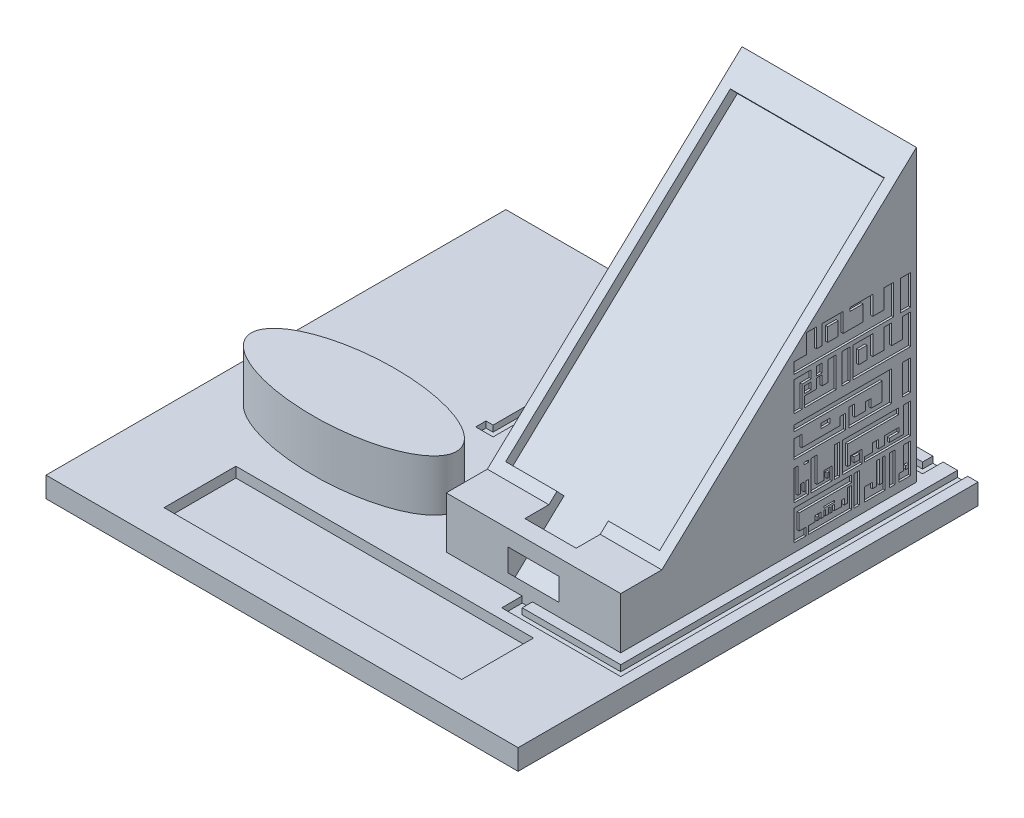
from build123d import *

# Parameters (mm, degrees)
SKETCH1_W           = 230
SKETCH1_H           = 224.05
BOSS_EXTRUDE1_DEPTH = 10
SKETCH1_5_RX        = 50
SKETCH1_5_RY        = 20
BOSS_EXTRUDE2_DEPTH = 25
SKETCH1_6_W         = 85
SKETCH1_6_H         = 144.05
BOSS_EXTRUDE3_DEPTH = 25
SKETCH1_8_W         = 145
SKETCH1_8_H         = 35
CUT_EXTRUDE1_DEPTH  = 5
BOSS_EXTRUDE6_START = -85
BOSS_EXTRUDE6_DEPTH = 85
SKETCH5_W           = 75
SKETCH5_H           = 150
CUT_EXTRUDE2_DEPTH  = 5
SKETCH5_3_W         = 25
SKETCH5_3_H         = 32.573742965
CUT_EXTRUDE3_DEPTH  = 8
SKETCH6_W           = 25
SKETCH6_H           = 32.807391054
CUT_EXTRUDE4_DEPTH  = 5
CUT_EXTRUDE5_DEPTH  = 3
CUT_EXTRUDE6_DEPTH  = 3
SKETCH14_W          = 5.229620034
SKETCH14_H          = 4.516490029
SKETCH14_W_2        = 4.754232759
SKETCH14_H_2        = 13.311760086
SKETCH14_W_3        = 4.754200031
SKETCH14_H_3        = 4.873055031
SKETCH14_W_4        = 55.86185036
SKETCH14_H_4        = 5.229620033
SKETCH14_H_5        = 4.783913781
SKETCH14_H_6        = 4.75420003
SKETCH14_W_5        = 4.991910032
SKETCH14_H_7        = 5.467330035
CUT_EXTRUDE7_DEPTH  = 3
SKETCH17_W          = 4.784873494
SKETCH17_H          = 14.625062341
SKETCH17_W_2        = 5.056431727
SKETCH17_H_2        = 6.616613386
SKETCH17_W_3        = 4.033370346
SKETCH17_H_3        = 6.231694953
SKETCH17_W_4        = 3.850934299
SKETCH17_W_5        = 4.288159487
SKETCH17_H_4        = 2.311035872
SKETCH17_W_6        = 2.611427715
SKETCH17_H_5        = 2.528019296
SKETCH17_W_7        = 1.087445954
SKETCH17_H_6        = 2.328438825
SKETCH17_W_8        = 1.416095815
SKETCH17_H_7        = 1.630432615
SKETCH17_W_9        = 2.674999894
SKETCH17_W_10       = 1.152737166
SKETCH17_W_11       = 2.717633131
SKETCH17_H_8        = 4.191921215
SKETCH17_W_12       = 3.241166829
SKETCH17_H_9        = 3.24997267
SKETCH17_W_13       = 2.608209419
SKETCH17_W_14       = 2.105340551
SKETCH17_H_10       = 1.029150801
SKETCH17_W_15       = 5.118075179
SKETCH17_H_11       = 0.779004841
CUT_EXTRUDE9_DEPTH  = 1
SKETCH18_W          = 210
SKETCH18_H          = 45.56820705
SKETCH18_W_2        = 57.268152104
SKETCH18_H_2        = 92.9135859
CUT_EXTRUDE10_DEPTH = 3


with BuildPart() as part:
    # Sketch1 → Boss-Extrude1 (new body)
    with BuildSketch(Plane(origin=(0, 0, 0), x_dir=(1, 0, 0), z_dir=(0, 1, 0))):
        with Locations((24.512599184, 69.589828777)):
            Rectangle(SKETCH1_W, SKETCH1_H)
    extrude(amount=-BOSS_EXTRUDE1_DEPTH)

    # Sketch1_5 → Boss-Extrude2 (add)
    with BuildSketch(Plane(origin=(0, 0, 0), x_dir=(1, 0, 0), z_dir=(0, 1, 0))):
        with Locations(Location((-25.487400816, 42.564828777), (0, 0, 0))):
            Ellipse(SKETCH1_5_RX, SKETCH1_5_RY)
    extrude(amount=BOSS_EXTRUDE2_DEPTH)

    # Sketch1_6 → Boss-Extrude3 (add)
    with BuildSketch(Plane(origin=(0, 0, 0), x_dir=(1, 0, 0), z_dir=(0, 1, 0))):
        with Locations((82.012599184, 94.589828777)):
            Rectangle(SKETCH1_6_W, SKETCH1_6_H)
    extrude(amount=BOSS_EXTRUDE3_DEPTH)

    # Sketch1_8 → Cut-Extrude1 (cut)
    with BuildSketch(Plane(origin=(0, 0, 0), x_dir=(1, 0, 0), z_dir=(0, 1, 0))):
        with Locations((24.512599184, -9.935171223)):
            Rectangle(SKETCH1_8_W, SKETCH1_8_H)
    extrude(amount=-CUT_EXTRUDE1_DEPTH, mode=Mode.SUBTRACT)

    # Sketch3 → Boss-Extrude6 (add)
    with BuildSketch(Plane.ZY.offset(-39.512599184).offset(BOSS_EXTRUDE6_START)):
        Polygon((-166.618882831, 25), (-166.618882831, 141.235070752), (-42.564828777, 25), align=None)
    extrude(amount=BOSS_EXTRUDE6_DEPTH)

    # Sketch5 → Cut-Extrude2 (cut)
    with BuildSketch(Plane(origin=(0, -7.924755547, -7.425267387), x_dir=(1, 0, 0), z_dir=(0, 0.72972973, 0.68373571))):
        with Locations((82.012599184, 128.554197404)):
            Rectangle(SKETCH5_W, SKETCH5_H)
    extrude(amount=-CUT_EXTRUDE2_DEPTH, mode=Mode.SUBTRACT)

    # Sketch5_3 → Cut-Extrude3 (cut)
    with BuildSketch(Plane(origin=(0, -7.924755547, -7.425267387), x_dir=(1, 0, 0), z_dir=(0, 0.72972973, 0.68373571))):
        with Locations((82.012599184, 31.867342275)):
            Rectangle(SKETCH5_3_W, SKETCH5_3_H)
    extrude(amount=CUT_EXTRUDE3_DEPTH, mode=Mode.SUBTRACT)

    # Sketch6 → Cut-Extrude4 (cut)
    with BuildSketch(Plane(origin=(0, -7.924755547, -7.425267387), x_dir=(1, 0, 0), z_dir=(0, 0.72972973, 0.68373571))):
        with Locations((82.012599184, 37.150501877)):
            Rectangle(SKETCH6_W, SKETCH6_H)
    extrude(amount=-CUT_EXTRUDE4_DEPTH, mode=Mode.SUBTRACT)

    # Sketch7 → Cut-Extrude5 (cut)
    with BuildSketch(Plane(origin=(0, 0, 0), x_dir=(1, 0, 0), z_dir=(0, 1, 0))):
        Polygon((81.512599184, 22.564828777), (76.512599184, 22.564828777), (76.512599184, 12.564828777), (134.512599184, 12.564828777), (134.512599184, 181.614828777), (129.512599184, 181.614828777), (129.512599184, 17.564828777), (81.512599184, 17.564828777), align=None)
    extrude(amount=-CUT_EXTRUDE5_DEPTH, mode=Mode.SUBTRACT)

    # Sketch7_3 → Cut-Extrude6 (cut)
    with BuildSketch(Plane(origin=(0, 0, 0), x_dir=(1, 0, 0), z_dir=(0, 1, 0))):
        Polygon((122.512599184, 181.614828777), (122.512599184, 171.614828777), (2.319740426, 171.614828777), (2.319740426, 82.564828777), (-6.151618198, 82.564828777), (-6.151618198, 87.564828777), (-2.680259574, 87.564828777), (-2.680259574, 176.614828777), (117.512599184, 176.614828777), (117.512599184, 181.614828777), align=None)
    extrude(amount=-CUT_EXTRUDE6_DEPTH, mode=Mode.SUBTRACT)

    # Sketch14 → Cut-Extrude7 (cut)
    with BuildSketch(Plane(origin=(0, 0, -166.618882831), x_dir=(-1, 0, 0), z_dir=(0, 0, -1))):
        Polygon((-53.021234882, 137.000333612), (-53.021234882, 122.975443522), (-103.415787935, 122.975443522), (-103.415787935, 103.720933398), (-108.88311797, 103.720933398), (-108.88311797, 136.473295075), (-93.43196787, 136.473295075), (-93.43196787, 127.440315017), (-88.67776784, 127.440315017), (-88.67776784, 136.473295075), (-82.972727803, 136.473295075), (-82.972727803, 127.440315017), (-78.218527772, 127.440315017), (-78.218527772, 136.473295075), (-73.22661774, 136.473295075), (-73.22661774, 127.440315017), (-68.234707708, 127.440315017), (-68.234707708, 136.473295075), (-63.005087674, 136.473295075), (-63.005087674, 127.967353554), (-57.775467641, 127.967353554), (-57.775467641, 137.000333612), align=None)
        with Locations((-100.800977918, 130.225598569)):
            Rectangle(SKETCH14_W, SKETCH14_H, mode=Mode.SUBTRACT)
        with Locations((-55.398351262, 110.376813441)):
            Rectangle(SKETCH14_W_2, SKETCH14_H_2)
        Polygon((-63.005087674, 117.032693484), (-63.005087674, 103.720933398), (-98.186167901, 103.720933398), (-98.186167901, 117.032693484), (-82.972727803, 117.032693484), (-82.972727803, 108.475133429), (-78.218527772, 108.475133429), (-78.218527772, 117.032693484), (-73.22661774, 117.032693484), (-73.22661774, 108.475133429), (-68.234707708, 108.475133429), (-68.234707708, 117.032693484), align=None)
        with Locations((-92.017976124, 110.911660944)):
            Rectangle(SKETCH14_W_3, SKETCH14_H_3, mode=Mode.SUBTRACT)
        with Locations((-81.915301059, 95.876503348)):
            Rectangle(SKETCH14_W_4, SKETCH14_H_4)
        Polygon((-53.984375879, 87.505641567), (-58.73857591, 87.505641567), (-58.73857591, 58.793743109), (-63.968195944, 58.793743109), (-63.968195944, 68.539853172), (-69.197815977, 68.539853172), (-69.197815977, 58.793743109), (-89.640876109, 58.793743109), (-89.640876109, 54.27725308), (-53.984375879, 54.27725308), align=None)
        Polygon((-109.846226239, 88.032073297), (-109.846226239, 84.228713273), (-69.197815977, 84.228713273), (-69.197815977, 78.523673236), (-99.14927617, 78.523673236), (-99.14927617, 58.793743109), (-104.378896204, 58.793743109), (-104.378896204, 78.523673236), (-109.846226239, 78.523673236), (-109.846226239, 54.27725308), (-94.39507614, 54.27725308), (-94.39507614, 73.412908203), (-89.522021108, 73.412908203), (-89.522021108, 63.845080642), (-74.18972601, 63.845080642), (-74.18972601, 73.412908203), (-63.968195944, 73.412908203), (-63.968195944, 88.032073297), align=None)
        with Locations((-81.796446059, 71.020951313)):
            Rectangle(SKETCH14_W_3, SKETCH14_H_5, mode=Mode.SUBTRACT)
        with Locations((-81.915301059, 45.906391299)):
            Rectangle(SKETCH14_W_4, SKETCH14_H_6)
        Polygon((-58.73857591, 38.061961248), (-58.73857591, 9.299051063), (-63.968195944, 9.299051063), (-63.968195944, 19.045161126), (-69.197815977, 19.045161126), (-69.197815977, 9.299051063), (-109.846226239, 9.299051063), (-109.846226239, 4.782561034), (-53.984375879, 4.782561034), (-53.984375879, 38.061961248), align=None)
        Polygon((-79.419346043, 38.061961248), (-63.968195944, 38.061961248), (-63.968195944, 23.680506156), (-89.522021108, 23.680506156), (-89.522021108, 33.307761218), (-94.39507614, 33.307761218), (-94.39507614, 23.680506156), (-104.378896204, 23.680506156), (-104.378896204, 19.045161126), (-76.745108526, 19.045161126), (-76.745108526, 14.172106095), (-109.846226239, 14.172106095), (-109.846226239, 38.061961248), (-84.173546074, 38.061961248), (-84.173546074, 28.494133687), (-69.197815977, 28.494133687), (-69.197815977, 33.278047468), (-79.419346043, 33.278047468), align=None)
        with Locations((-101.882941188, 31.100527931)):
            Rectangle(SKETCH14_W_5, SKETCH14_H_7, mode=Mode.SUBTRACT)
    extrude(amount=-CUT_EXTRUDE7_DEPTH, mode=Mode.SUBTRACT)

    # Sketch17 → Cut-Extrude9 (cut)
    with BuildSketch(Plane(origin=(124.512599184, 0, 0), x_dir=(0, 0, -1), z_dir=(1, 0, 0))):
        with Locations((161.358444461, 82.562943082)):
            Rectangle(SKETCH17_W, SKETCH17_H)
        Polygon((150.701585499, 89.875474252), (155.486458993, 89.875474252), (155.486458993, 75.250411911), (107.031739009, 75.250411911), (107.031739009, 80.566938016), (113.184412967, 80.566938016), (113.184412967, 89.875474252), (117.969286461, 89.875474252), (117.969286461, 80.566938016), (120.731293394, 80.566938016), (120.731293394, 89.875474252), (130.895478905, 89.875474252), (130.895478905, 80.566938016), (140.617743308, 80.566938016), (140.617743308, 88.207938914), (134.314603894, 88.207938914), (134.314603894, 89.875474252), (145.354158386, 89.875474252), (145.354158386, 80.566938016), (150.701585499, 80.566938016), align=None)
        with Locations((125.911035913, 83.875244709)):
            Rectangle(SKETCH17_W_2, SKETCH17_H_2, mode=Mode.SUBTRACT)
        Polygon((159.899946909, 73.250570314), (163.750881208, 73.250570314), (163.750881208, 58.625507973), (159.899946909, 58.625507973), (135.751693469, 58.625507973), (135.751693469, 73.250570314), (145.354158386, 73.250570314), (145.354158386, 63.595554709), (150.701585499, 63.595554709), (150.701585499, 73.250570314), (154.552519797, 73.250570314), (154.552519797, 63.595554709), (159.899946909, 63.595554709), align=None)
        with Locations((140.496529885, 66.711402186)):
            Rectangle(SKETCH17_W_3, SKETCH17_H_3, mode=Mode.SUBTRACT)
        with Locations((132.389136745, 65.938039144)):
            Rectangle(SKETCH17_W_4, SKETCH17_H)
        Polygon((123.580677252, 73.250570314), (123.580677252, 63.595554709), (120.668230643, 63.595554709), (120.668230643, 68.259457278), (117.950597512, 68.259457278), (117.950597512, 63.595554709), (112.089138513, 63.595554709), (112.089138513, 58.625507973), (127.431611551, 58.625507973), (127.431611551, 73.250570314), align=None)
        Polygon((110.890350782, 58.625507973), (110.890350782, 69.251812479), (115.330305342, 69.251812479), (115.330305342, 73.044925366), (107.059571093, 73.044925366), (107.059571093, 58.625507973), align=None)
        with Locations((161.825414059, 46.577329301)):
            Rectangle(SKETCH17_W_4, SKETCH17_H)
        Polygon((107.059571093, 51.04770813), (107.059571093, 53.889860471), (154.552519797, 53.889860471), (154.552519797, 39.26479813), (133.767966115, 39.26479813), (133.767966115, 48.093772288), (136.485599246, 48.093772288), (136.485599246, 42.418454363), (141.833026358, 42.418454363), (141.833026358, 46.323617152), (144.550659489, 46.323617152), (144.550659489, 42.211690672), (149.898086601, 42.211690672), (149.898086601, 51.04770813), align=None)
        with Locations((122.265856062, 46.938254352)):
            Rectangle(SKETCH17_W_5, SKETCH17_H_4)
        Polygon((129.393128825, 42.418454363), (129.393128825, 46.323617152), (132.110761956, 46.323617152), (132.110761956, 39.26479813), (107.059571093, 39.26479813), (107.059571093, 48.093772288), (110.817070949, 48.093772288), (110.817070949, 42.418454363), align=None)
        Polygon((153.409664033, 25.173026295), (153.409664033, 23.310275235), (160.388254878, 23.310275235), (160.388254878, 35.688715797), (163.750881208, 35.688715797), (163.750881208, 21.063653456), (141.341401325, 21.063653456), (141.341401325, 23.310275235), (145.175199459, 23.310275235), (145.175199459, 27.301884649), (148.064438633, 27.301884649), (148.064438633, 23.310275235), (151.013572513, 23.310275235), (151.013572513, 27.368411473), (158.065106166, 27.368411473), (158.065106166, 25.173026295), align=None)
        Polygon((133.155654605, 32.823611006), (133.155654605, 23.310275235), (134.599510004, 23.310275235), (134.599510004, 27.168831002), (136.396357354, 27.168831002), (140.212726279, 27.168831002), (140.212726279, 21.063653456), (130.487101309, 21.063653456), (130.487101309, 35.688715797), (157.908861348, 35.688715797), (157.908861348, 32.823611006), align=None)
        with Locations((137.602192016, 24.574284883)):
            Rectangle(SKETCH17_W_6, SKETCH17_H_5, mode=Mode.SUBTRACT)
        Polygon((125.536954506, 21.181416881), (125.536954506, 21.063653456), (115.346413992, 21.063653456), (115.346413992, 35.688715797), (118.116658015, 35.688715797), (118.116658015, 23.310275235), (121.502989705, 23.310275235), (121.502989705, 27.368411473), (125.536954506, 27.368411473), align=None)
        with Locations((123.554840806, 24.474494648)):
            Rectangle(SKETCH17_W_7, SKETCH17_H_6, mode=Mode.SUBTRACT)
        Polygon((112.870105988, 27.434938297), (113.922776263, 27.434938297), (113.922776263, 21.063653456), (107.059571093, 21.063653456), (107.059571093, 35.688715797), (108.869958942, 35.688715797), (108.869958942, 23.310275235), (110.133163272, 23.310275235), (110.133163272, 27.434938297), (111.817435712, 27.434938297), (111.817435712, 23.310275235), (112.870105988, 23.310275235), align=None)
        Polygon((160.384839223, 18.829973358), (160.384839223, 7.910481135), (158.228922378, 7.910481135), (158.228922378, 4.204911017), (163.747465553, 4.204911017), (163.747465553, 18.829973358), align=None)
        with Locations((162.110515543, 8.725697443)):
            Rectangle(SKETCH17_W_8, SKETCH17_H_7, mode=Mode.SUBTRACT)
        with Locations((154.74716398, 11.517442188)):
            Rectangle(SKETCH17_W_9, SKETCH17_H)
        with Locations((137.602192016, 11.517442188)):
            Rectangle(SKETCH17_W_6, SKETCH17_H)
        Polygon((112.866690333, 7.910481135), (112.866690333, 4.204911017), (107.059571093, 4.204911017), (107.059571093, 18.829973358), (135.10327146, 18.829973358), (135.10327146, 15.580435784), (109.498145453, 15.580435784), (109.498145453, 7.910481135), align=None)
        Polygon((133.152238951, 7.910481135), (133.152238951, 10.626103709), (133.152238951, 14.46100203), (135.10327146, 14.46100203), (135.10327146, 10.626103709), (135.10327146, 4.204911017), (113.919360608, 4.204911017), (113.919360608, 7.910481135), (117.302175503, 7.910481135), (117.302175503, 10.626103709), (120.091988092, 10.626103709), (120.091988092, 7.910481135), (121.499574051, 7.910481135), (121.499574051, 10.626103709), (122.372025777, 10.626103709), (122.372025777, 7.910481135), (123.667713733, 7.910481135), (123.667713733, 10.626103709), (124.511316034, 10.626103709), (124.511316034, 7.910481135), (125.533538852, 7.910481135), (125.533538852, 10.626103709), (126.61764923, 10.626103709), (126.61764923, 7.910481135), (130.069228306, 7.910481135), (130.069228306, 10.626103709), (131.462339947, 10.626103709), (131.462339947, 7.910481135), align=None)
        with Locations((118.689610943, 8.725697443)):
            Rectangle(SKETCH17_W_10, SKETCH17_H_7, mode=Mode.SUBTRACT)
        with Locations((119.309414078, 71.154609706)):
            Rectangle(SKETCH17_W_11, SKETCH17_H_8)
        with Locations((113.709721927, 66.28808042)):
            Rectangle(SKETCH17_W_12, SKETCH17_H_9)
        with Locations((127.925169594, 28.376184626)):
            Rectangle(SKETCH17_W_13, SKETCH17_H)
        with Locations((112.870105988, 35.174140397)):
            Rectangle(SKETCH17_W_14, SKETCH17_H_10)
        Polygon((151.399094392, 18.829973358), (151.399094392, 4.204911017), (141.33798567, 4.204911017), (141.33798567, 10.626103709), (145.171783805, 10.626103709), (145.171783805, 7.910481135), (147.159769575, 7.910481135), (147.159769575, 18.829973358), (148.51502462, 18.829973358), (148.51502462, 7.910481135), (150.00457965, 7.910481135), (150.00457965, 18.829973358), align=None)
        with Locations((124.058611641, 11.911034162)):
            Rectangle(SKETCH17_W_15, SKETCH17_H_11)
    extrude(amount=-CUT_EXTRUDE9_DEPTH, mode=Mode.SUBTRACT)

    # Sketch18 → Cut-Extrude10 (cut)
    with BuildSketch(Plane.XZ.offset(10)):
        with Locations((24.512599184, 9.651067698)):
            Rectangle(SKETCH18_W, SKETCH18_H)
        with Locations((-51.853324764, -69.589828777)):
            Rectangle(SKETCH18_W_2, SKETCH18_H_2)
        with Locations((100.878523132, -69.589828777)):
            Rectangle(SKETCH18_W_2, SKETCH18_H_2)
        with Locations((24.512599184, -148.830725252)):
            Rectangle(SKETCH18_W, SKETCH18_H)
    extrude(amount=-CUT_EXTRUDE10_DEPTH, mode=Mode.SUBTRACT)


solid = part.part
